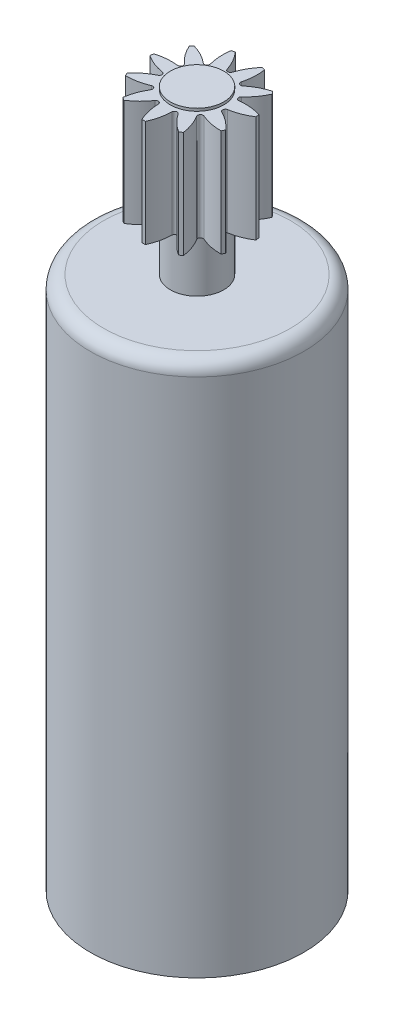
from build123d import *

# Parameters (mm, degrees)
CUT_EXTRUDE1_DEPTH = 5
CIRPATTERN1_COUNT  = 11


with BuildPart() as part:
    # Sketch1 → Revolve1 (revolve)
    with BuildSketch(Plane.XY):
        with BuildLine():
            Line((0, 0), (0, 26.1))
            Line((0, 26.1), (1, 26.1))
            Line((1, 26.1), (1, 26))
            Line((1, 26), (2, 26))
            Line((2, 26), (2, 22))
            Line((2, 22), (1, 22))
            Line((1, 22), (1, 20))
            Line((1, 20), (3.5, 20))
            ThreePointArc((3.5, 20), (3.853553391, 19.853553391), (4, 19.5))
            Line((4, 19.5), (4, 0))
            Line((4, 0), (0, 0))
        make_face()
    revolve(axis=Axis((0, 0, 0), (0, 1, 0)))

    # Sketch2 → Cut-Extrude1 (cut)
    with BuildSketch(Plane(origin=(0, 26, 0), x_dir=(1, 0, 0), z_dir=(0, 1, 0))):
        with BuildLine():
            ThreePointArc((-0.5, 1.936491673), (0, 2), (0.5, 1.936491673))
            ThreePointArc((0.5, 1.936491673), (0.260400333, 1.599188187), (0.095331419, 1.219801979))
            ThreePointArc((0.095331419, 1.219801979), (0, 1.15), (-0.095331419, 1.219801979))
            ThreePointArc((-0.095331419, 1.219801979), (-0.260400333, 1.599188187), (-0.5, 1.936491673))
        make_face()
    cut_extrude1 = extrude(amount=-CUT_EXTRUDE1_DEPTH, mode=Mode.SUBTRACT)

    # CirPattern1: Cut-Extrude1 ×11 about axis
    cirpattern1_axis = Axis((0, 0, 0), (0, 1, 0))
    for i in range(1, CIRPATTERN1_COUNT):
        add(cut_extrude1.rotate(cirpattern1_axis, i * 360 / CIRPATTERN1_COUNT), mode=Mode.SUBTRACT)


solid = part.part
